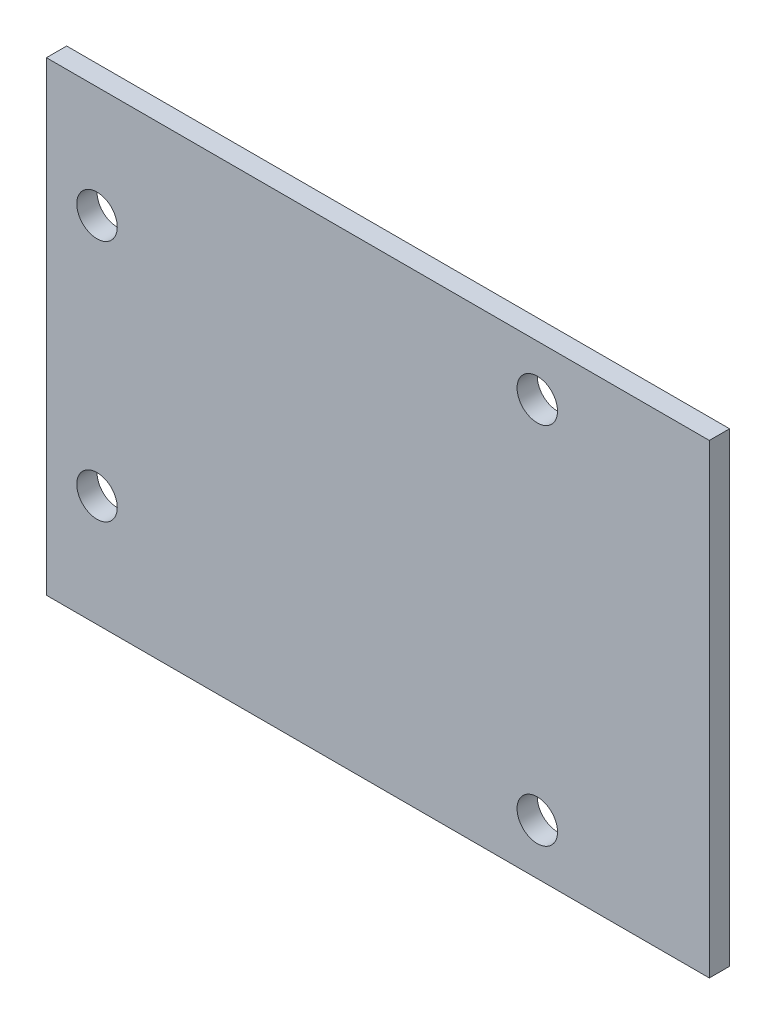
from build123d import *

# Parameters (mm, degrees)
ESQUISSE1_W             = 65.5
ESQUISSE1_H             = 46
BOSS_EXTRU_1_DEPTH      = 2
ESQUISSE2_R             = 2
ENL_V_MAT_EXTRU_1_DEPTH = 3


with BuildPart() as part:
    # Esquisse1 → Boss.-Extru.1 (new body)
    with BuildSketch(Plane.XY):
        with Locations((32.75, 23)):
            Rectangle(ESQUISSE1_W, ESQUISSE1_H)
    extrude(amount=BOSS_EXTRU_1_DEPTH)

    # Esquisse2 → Enlèv. mat.-Extru.1 (cut, through all)
    with BuildSketch(Plane.XY.offset(2)):
        with Locations((5, 11)):
            Circle(ESQUISSE2_R)
        with Locations((5, 35)):
            Circle(ESQUISSE2_R)
        with Locations((48.5, 41)):
            Circle(ESQUISSE2_R)
        with Locations((48.5, 5)):
            Circle(ESQUISSE2_R)
    extrude(amount=-ENL_V_MAT_EXTRU_1_DEPTH, mode=Mode.SUBTRACT)


solid = part.part
